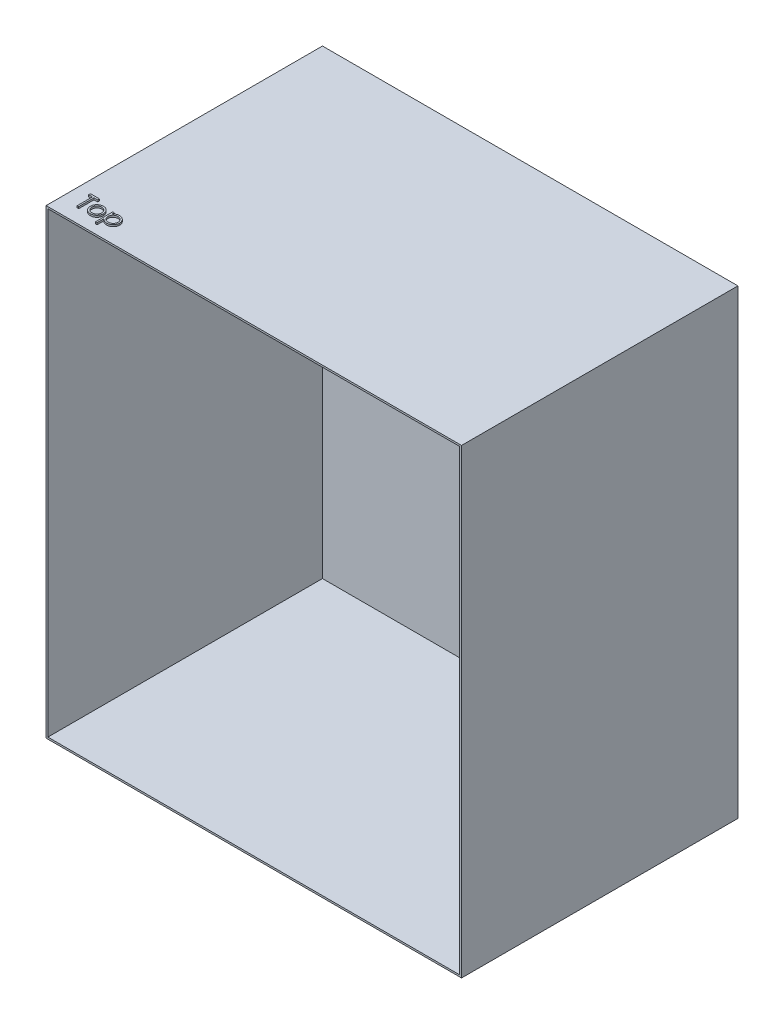
from build123d import *

# Parameters (mm, degrees)
SKETCH1_W           = 461.2
SKETCH1_H           = 512
BOSS_EXTRUDE1_DEPTH = 2
SKETCH1_6_W         = 461.2
SKETCH1_6_H         = 512
SKETCH1_6_W_2       = 457.2
SKETCH1_6_H_2       = 508
BOSS_EXTRUDE4_DEPTH = 304.8
BOSS_EXTRUDE5_DEPTH = 2


with BuildPart() as part:
    # Sketch1 → Boss-Extrude1 (new body)
    with BuildSketch(Plane.XY):
        Rectangle(SKETCH1_W, SKETCH1_H)
    extrude(amount=-BOSS_EXTRUDE1_DEPTH)

    # Sketch1_6 → Boss-Extrude4 (add)
    with BuildSketch(Plane.XY):
        Rectangle(SKETCH1_6_W, SKETCH1_6_H)
        Rectangle(SKETCH1_6_W_2, SKETCH1_6_H_2, mode=Mode.SUBTRACT)
    extrude(amount=BOSS_EXTRUDE4_DEPTH)

    # Sketch4 → Boss-Extrude5 (add)
    # profile 1 of 3: a face of its own
    with BuildSketch(Plane(origin=(0, 256, 0), x_dir=(1, 0, 0), z_dir=(0, 1, 0))):
        Polygon((-215.355769231, -272.703846154), (-215.355769231, -270.75), (-205.342307692, -270.75), (-205.342307692, -272.703846154), (-209.494230769, -272.703846154), (-209.494230769, -289.8), (-211.203846154, -289.8), (-211.203846154, -272.703846154), align=None)
    # profile 2 of 3: a face of its own
    with BuildSketch(Plane(origin=(0, 256, 0), x_dir=(1, 0, 0), z_dir=(0, 1, 0))):
        with BuildLine():
            add(Edge.make_bspline(
                [(-196.176021635, -275.634615385), (-195.914811992, -275.640177392), (-195.402643721, -275.651083129), (-194.652575085, -275.767641728), (-193.936593702, -275.945880954), (-193.251957427, -276.192287599), (-192.607434448, -276.522570787), (-191.993636676, -276.916684215), (-191.412246956, -277.383586617), (-191.063778754, -277.744764103), (-190.886899038, -277.928094952)],
                knots=[0, 0, 0, 0, 1.054011418, 2.066658804, 3.057071809, 4.030435133, 4.997543892, 5.974964718, 6.972108034, 8, 8, 8, 8], degree=3))
            add(Edge.make_bspline(
                [(-190.886899038, -277.928094952), (-190.73459726, -278.103431075), (-190.432941162, -278.450710083), (-190.046140607, -279.013804205), (-189.712920401, -279.596952467), (-189.445877713, -280.20789863), (-189.235320655, -280.841309341), (-189.085828794, -281.499361716), (-188.996909191, -282.180602491), (-188.984918757, -282.643266238), (-188.978846154, -282.877584135)],
                knots=[0, 0, 0, 0, 1.025258237, 2.030674902, 3.01204498, 3.988269485, 4.97094183, 5.956517959, 6.965070386, 8, 8, 8, 8], degree=3))
            add(Edge.make_bspline(
                [(-188.978846154, -282.877584135), (-188.984187433, -283.113260163), (-188.994742049, -283.578966986), (-189.094583732, -284.264872391), (-189.249874357, -284.929961354), (-189.472116219, -285.571449387), (-189.757093928, -286.191297348), (-190.104841813, -286.786797895), (-190.517800186, -287.359125935), (-190.985907654, -287.903421654), (-191.503261437, -288.405069195), (-192.064507902, -288.84228449), (-192.658617714, -289.216870216), (-193.293490823, -289.518602707), (-193.963329572, -289.756508361), (-194.669578757, -289.923604165), (-195.411141211, -290.024632758), (-195.917475088, -290.037606207), (-196.176021635, -290.044230769)],
                knots=[0, 0, 0, 0, 0.998656419, 1.973391657, 2.932242238, 3.890759089, 4.846373663, 5.82037756, 6.809684879, 7.83454468, 8.860553229, 9.859544525, 10.845671541, 11.83227036, 12.833544569, 13.85385346, 14.904124723, 16, 16, 16, 16], degree=3))
            add(Edge.make_bspline(
                [(-196.176021635, -290.044230769), (-196.435834894, -290.037583973), (-196.944692287, -290.024565886), (-197.688872275, -289.923996676), (-198.396387201, -289.75658537), (-199.067102858, -289.517820874), (-199.704705525, -289.216860572), (-200.302257744, -288.843416947), (-200.863960142, -288.404939531), (-201.381423371, -287.903456788), (-201.849501494, -287.359116883), (-202.26246744, -286.786800244), (-202.610213358, -286.191296736), (-202.895191582, -285.571449551), (-203.117433306, -284.929961311), (-203.272723968, -284.264872403), (-203.372565642, -283.578966983), (-203.383120259, -283.113260162), (-203.388461538, -282.877584135)],
                knots=[0, 0, 0, 0, 1.099876186, 2.154163076, 3.173186993, 4.173200201, 5.163417411, 6.152872554, 7.150605724, 8.17532212, 9.198891216, 10.186952605, 11.159729845, 12.11414092, 13.071450619, 14.029093627, 15.002601286, 16, 16, 16, 16], degree=3))
            add(Edge.make_bspline(
                [(-203.388461538, -282.877584135), (-203.382347521, -282.644539792), (-203.370242816, -282.183152045), (-203.281412617, -281.5031919), (-203.132503902, -280.846253254), (-202.921694444, -280.215287449), (-202.652190334, -279.607018576), (-202.323652467, -279.022429424), (-201.93290631, -278.461881539), (-201.632449973, -278.11505136), (-201.480408654, -277.939543269)],
                knots=[0, 0, 0, 0, 1.031353054, 2.041901799, 3.029428768, 4.008703097, 4.981709435, 5.96992636, 6.972712378, 8, 8, 8, 8], degree=3))
            add(Edge.make_bspline(
                [(-201.480408654, -277.939543269), (-201.303795608, -277.754622528), (-200.956454978, -277.390943353), (-200.372171189, -276.925402044), (-199.759883391, -276.523087413), (-199.108237721, -276.199366869), (-198.42416388, -275.944431508), (-197.704513432, -275.767182062), (-196.951899555, -275.651503087), (-196.437225045, -275.640300719), (-196.176021635, -275.634615385)],
                knots=[0, 0, 0, 0, 1.027980169, 2.021703884, 2.998553061, 3.971491411, 4.943284454, 5.930300938, 6.949603206, 8, 8, 8, 8], degree=3))
        make_face()
        with BuildLine():
            add(Edge.make_bspline(
                [(-196.183653846, -277.344230769), (-196.368371416, -277.349480904), (-196.733038102, -277.359845642), (-197.269810413, -277.438679466), (-197.786556108, -277.563579453), (-198.28425556, -277.741038673), (-198.761230398, -277.970176966), (-199.217937289, -278.251618183), (-199.655719569, -278.581634704), (-200.066013371, -278.959710102), (-200.442562813, -279.372708629), (-200.7717358, -279.812754697), (-201.051635307, -280.272710667), (-201.284808172, -280.753054845), (-201.458474439, -281.258654984), (-201.58460189, -281.783785277), (-201.663361341, -282.329515615), (-201.673628631, -282.7005063), (-201.678846154, -282.889032452)],
                knots=[0, 0, 0, 0, 1.021534396, 2.016698045, 2.994645724, 3.958388632, 4.93408049, 5.916473867, 6.921342795, 7.962252576, 8.998418191, 10.008913653, 10.997312074, 11.973003931, 12.956656626, 13.948281152, 14.957379055, 16, 16, 16, 16], degree=3))
            add(Edge.make_bspline(
                [(-201.678846154, -282.889032452), (-201.670100442, -283.132611343), (-201.65274184, -283.616069893), (-201.511580054, -284.328056146), (-201.27543473, -285.011580227), (-200.956552536, -285.662635128), (-200.557012975, -286.265008527), (-200.086276226, -286.80206332), (-199.549394428, -287.265717523), (-198.952767477, -287.650423268), (-198.308581833, -287.956092795), (-197.626829571, -288.172712934), (-196.915770936, -288.31352886), (-196.429828671, -288.327525028), (-196.183653846, -288.334615385)],
                knots=[0, 0, 0, 0, 1.016792936, 2.018143844, 3.017858371, 4.030088057, 5.03801393, 6.028138512, 7.003788237, 7.991172063, 8.984598303, 9.972568034, 10.972917682, 12, 12, 12, 12], degree=3))
            add(Edge.make_bspline(
                [(-196.183653846, -288.334615385), (-195.937493181, -288.327483716), (-195.451578866, -288.313406001), (-194.741508203, -288.17342214), (-194.061619299, -287.955143643), (-193.418102747, -287.650767044), (-192.821747377, -287.264256615), (-192.281004302, -286.804681477), (-191.814286862, -286.263586086), (-191.415142527, -285.661837251), (-191.091038113, -285.012589563), (-190.855998114, -284.327929992), (-190.714496968, -283.616102021), (-190.697184172, -283.132622107), (-190.688461538, -282.889032452)],
                knots=[0, 0, 0, 0, 1.02726834, 2.027799167, 3.010890988, 4.004497153, 4.992059811, 5.971914811, 6.958719428, 7.966827853, 8.981595046, 9.981490638, 10.983022906, 12, 12, 12, 12], degree=3))
            add(Edge.make_bspline(
                [(-190.688461538, -282.889032452), (-190.693677265, -282.700505174), (-190.70394102, -282.329512271), (-190.782726183, -281.783798059), (-190.908758477, -281.258608083), (-191.082775423, -280.753227894), (-191.314935127, -280.271466978), (-191.600232243, -279.814105178), (-191.92806111, -279.371184263), (-192.309154297, -278.961045161), (-192.719019825, -278.581487319), (-193.156979533, -278.251490214), (-193.613009202, -277.971413872), (-194.088598345, -277.739078763), (-194.586361606, -277.565193953), (-195.102383266, -277.437958288), (-195.63686536, -277.360178789), (-196.000225295, -277.349580776), (-196.183653846, -277.344230769)],
                knots=[0, 0, 0, 0, 1.042956736, 2.052379634, 3.044323526, 4.02829302, 5.004299113, 5.996692471, 7.007513377, 8.048758398, 9.090003419, 10.095195979, 11.07790575, 12.047570684, 13.018257071, 13.989683339, 14.985167495, 16, 16, 16, 16], degree=3))
        make_face(mode=Mode.SUBTRACT)
    # profile 3 of 3: a face of its own
    with BuildSketch(Plane(origin=(0, 256, 0), x_dir=(1, 0, 0), z_dir=(0, 1, 0))):
        with BuildLine():
            Line((-185.559615385, -275.878846154), (-183.85, -275.878846154))
            Line((-183.85, -275.878846154), (-183.85, -278.454717548))
            add(Edge.make_bspline(
                [(-183.85, -278.454717548), (-183.66843998, -278.221013597), (-183.315614414, -277.766856737), (-182.707511718, -277.179081894), (-182.065652944, -276.683372027), (-181.373520655, -276.294847098), (-180.641871714, -276.001908107), (-179.873708672, -275.785394244), (-179.062511966, -275.657805647), (-178.507904131, -275.642447748), (-178.225060096, -275.634615385)],
                knots=[0, 0, 0, 0, 1.0828784, 2.104357462, 3.088488658, 4.04616522, 5.001424249, 5.969181776, 6.964304535, 8, 8, 8, 8], degree=3))
            add(Edge.make_bspline(
                [(-178.225060096, -275.634615385), (-177.978000084, -275.64176283), (-177.489672992, -275.65589013), (-176.770871704, -275.751537756), (-176.078674259, -275.915464053), (-175.416996708, -276.151689036), (-174.778750596, -276.443728093), (-174.173384596, -276.812302244), (-173.591469386, -277.23905594), (-173.047639842, -277.730176646), (-172.545147827, -278.261553354), (-172.11055647, -278.833174752), (-171.735696534, -279.426242544), (-171.432691063, -280.049950931), (-171.195337058, -280.699388454), (-171.026528598, -281.377178968), (-170.926066281, -282.080809444), (-170.912587309, -282.559251394), (-170.905769231, -282.801262019)],
                knots=[0, 0, 0, 0, 1.041296284, 2.058176809, 3.050446431, 4.034000596, 5.01514041, 6.003636468, 7.015969324, 8.052561599, 9.08815499, 10.094063707, 11.074456064, 12.040834395, 13.011057502, 13.983766392, 14.980127149, 16, 16, 16, 16], degree=3))
            add(Edge.make_bspline(
                [(-170.905769231, -282.801262019), (-170.912439374, -283.048380299), (-170.925593858, -283.535733207), (-171.027620247, -284.251398694), (-171.190671234, -284.9398514), (-171.425030773, -285.59994622), (-171.727879446, -286.231228665), (-172.096385696, -286.833243478), (-172.531196324, -287.405797776), (-173.028135319, -287.941118561), (-173.567266299, -288.434237679), (-174.143542349, -288.865519172), (-174.748020215, -289.227694372), (-175.377607297, -289.53022448), (-176.037693272, -289.758237653), (-176.725198398, -289.922708825), (-177.439748366, -290.024133724), (-177.925801779, -290.037480385), (-178.171634615, -290.044230769)],
                knots=[0, 0, 0, 0, 1.038740735, 2.04854663, 3.033179607, 4.009277356, 4.987731542, 5.972001279, 6.972200261, 8.005528982, 9.039189865, 10.040446548, 11.026516639, 11.997840187, 12.972163198, 13.956796175, 14.96660207, 16, 16, 16, 16], degree=3))
            add(Edge.make_bspline(
                [(-178.171634615, -290.044230769), (-178.448281828, -290.037183316), (-178.994741181, -290.023262529), (-179.79373993, -289.882186883), (-180.562689652, -289.671347276), (-181.293071141, -289.362742754), (-181.990670235, -288.969466303), (-182.651540892, -288.489895039), (-183.279193504, -287.925031924), (-183.656975455, -287.496505896), (-183.85, -287.277554087)],
                knots=[0, 0, 0, 0, 1.014726462, 2.004382257, 2.969841629, 3.936926163, 4.907207904, 5.903978561, 6.929055279, 8, 8, 8, 8], degree=3))
            Line((-183.85, -287.277554087), (-183.85, -294.928846154))
            Line((-183.85, -294.928846154), (-185.559615385, -294.928846154))
            Line((-185.559615385, -294.928846154), (-185.559615385, -275.878846154))
        make_face()
        with BuildLine():
            add(Edge.make_bspline(
                [(-178.240324519, -277.344230769), (-178.433978995, -277.347715603), (-178.815234743, -277.354576343), (-179.374064963, -277.436077407), (-179.912338649, -277.554392827), (-180.424630984, -277.733527598), (-180.915852197, -277.953412567), (-181.382218865, -278.228178943), (-181.823403625, -278.552856289), (-182.238296462, -278.921225289), (-182.613109531, -279.327124663), (-182.944922039, -279.760309738), (-183.223636085, -280.220231927), (-183.45496851, -280.702607114), (-183.631008377, -281.211216452), (-183.75595308, -281.743163278), (-183.834495429, -282.299029827), (-183.844776645, -282.677613234), (-183.85, -282.869951923)],
                knots=[0, 0, 0, 0, 1.05670511, 2.080379991, 3.077984906, 4.06214886, 5.038337365, 6.01289324, 7.01187578, 8.025460281, 9.038092164, 10.024533457, 11.000252242, 11.969694649, 12.940728589, 13.933144304, 14.949937299, 16, 16, 16, 16], degree=3))
            add(Edge.make_bspline(
                [(-183.85, -282.869951923), (-183.841341198, -283.122435793), (-183.82437787, -283.617073077), (-183.686470196, -284.339798083), (-183.462032544, -285.023702094), (-183.143469117, -285.663025738), (-182.740983034, -286.250760884), (-182.256034497, -286.777034042), (-181.69301147, -287.238537116), (-181.061274326, -287.627272797), (-180.384062444, -287.942893558), (-179.677656265, -288.168849475), (-178.951770271, -288.308035461), (-178.460996988, -288.325707433), (-178.213611779, -288.334615385)],
                knots=[0, 0, 0, 0, 1.03728447, 2.032128127, 3.01272805, 3.987917167, 4.958271349, 5.931593992, 6.91984656, 7.941419022, 8.973179163, 9.983609215, 10.983593296, 12, 12, 12, 12], degree=3))
            add(Edge.make_bspline(
                [(-178.213611779, -288.334615385), (-177.971209956, -288.326144248), (-177.490085916, -288.309330564), (-176.781653855, -288.163798428), (-176.09318338, -287.941484795), (-175.43905987, -287.617310637), (-174.824977743, -287.220036179), (-174.270451002, -286.743459427), (-173.785999087, -286.191064164), (-173.37308024, -285.575975027), (-173.040350298, -284.916434725), (-172.790358564, -284.234001738), (-172.646076187, -283.53108165), (-172.625628523, -283.057565527), (-172.615384615, -282.820342548)],
                knots=[0, 0, 0, 0, 1.00104056, 1.986885549, 2.97790532, 3.984399681, 4.995088187, 5.994304198, 6.996462723, 8.023150851, 9.048424203, 10.043036403, 11.019596776, 12, 12, 12, 12], degree=3))
            add(Edge.make_bspline(
                [(-172.615384615, -282.820342548), (-172.623302524, -282.581646107), (-172.639076652, -282.106112912), (-172.7944541, -281.405274825), (-173.02795255, -280.720084556), (-173.368452533, -280.069551278), (-173.772319443, -279.455738056), (-174.260799526, -278.913880515), (-174.80843911, -278.439422996), (-175.421790131, -278.047453408), (-176.080051589, -277.735656643), (-176.773008489, -277.50768998), (-177.49714581, -277.370672858), (-177.990419187, -277.35312233), (-178.240324519, -277.344230769)],
                knots=[0, 0, 0, 0, 0.983928682, 1.960191568, 2.949917689, 3.96440592, 4.982380491, 5.975291189, 6.965713506, 7.964880129, 8.970154049, 9.96478489, 10.968906225, 12, 12, 12, 12], degree=3))
        make_face(mode=Mode.SUBTRACT)
    extrude(amount=BOSS_EXTRUDE5_DEPTH)


solid = part.part
